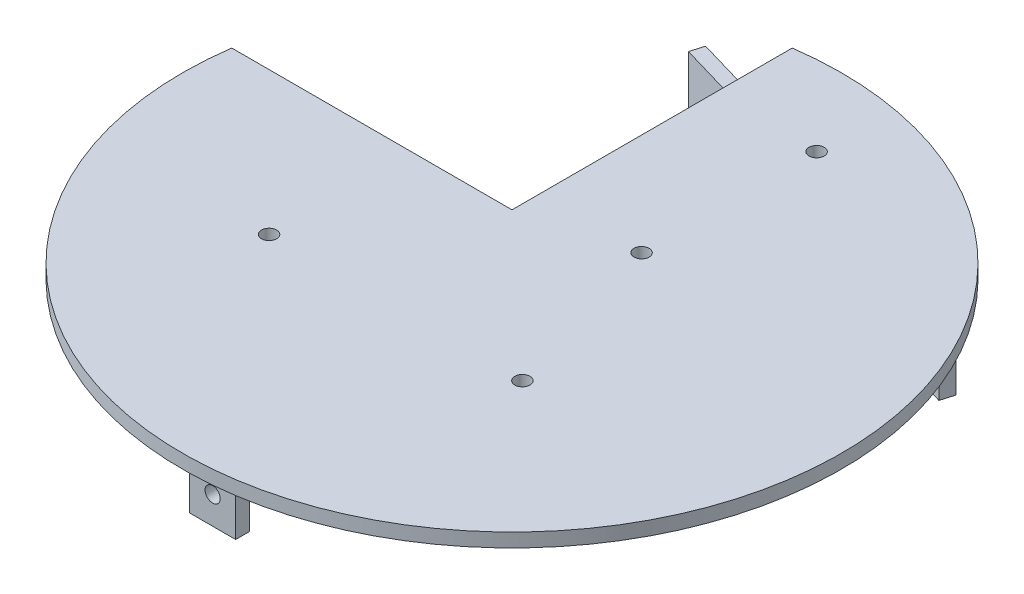
from build123d import *

# Parameters (mm, degrees)
SKETCH1_R           = 1.65
BOSS_EXTRUDE1_DEPTH = 3
BOSS_EXTRUDE2_DEPTH = 16
SKETCH3_R           = 1.65
CUT_EXTRUDE1_DEPTH  = 16
SKETCH5_W           = 10
SKETCH5_H           = 3
BOSS_EXTRUDE3_DEPTH = 14
SKETCH6_R           = 1.65
CUT_EXTRUDE2_DEPTH  = 14


with BuildPart() as part:
    # Sketch1 → Boss-Extrude1 (new body)
    with BuildSketch(Plane(origin=(0, 0, 0), x_dir=(1, 0, 0), z_dir=(0, 1, 0))):
        with BuildLine():
            Line((-10, 70.842692107), (-10, 10))
            Line((-10, 10), (-70.842692107, 10))
            ThreePointArc((-70.842692107, 10), (-71.369207057, 5.012315742), (-71.545, 0))
            ThreePointArc((-71.545, 0), (50.58995466, -50.58995466), (0, 71.545))
            ThreePointArc((0, 71.545), (-5.012315742, 71.369207057), (-10, 70.842692107))
        make_face()
        with Locations((12.13, 16)):
            Circle(SKETCH1_R, mode=Mode.SUBTRACT)
        with Locations((12.13, 54)):
            Circle(SKETCH1_R, mode=Mode.SUBTRACT)
        with Locations((23.25, -21)):
            Circle(SKETCH1_R, mode=Mode.SUBTRACT)
        with Locations((-31.75, -21)):
            Circle(SKETCH1_R, mode=Mode.SUBTRACT)
    extrude(amount=BOSS_EXTRUDE1_DEPTH)

    # Sketch2 → Boss-Extrude2 (add)
    with BuildSketch(Plane.XZ):
        Polygon((-23.600230141, -61.909816502), (53.19593923, -39.496687094), (54.036431583, -42.376543445), (-22.759737789, -64.789672853), align=None)
    extrude(amount=BOSS_EXTRUDE2_DEPTH)

    # Sketch3 → Cut-Extrude1 (cut)
    with BuildSketch(Plane(origin=(14.797854544, 0, -50.703251798), x_dir=(0.959952117, 0, 0.280164118), z_dir=(-0.280164118, 0, 0.959952117))):
        with Locations((-31, -8)):
            Circle(SKETCH3_R)
        with Locations((31, -8)):
            Circle(SKETCH3_R)
    extrude(amount=-CUT_EXTRUDE1_DEPTH, mode=Mode.SUBTRACT)

    # Sketch5 → Boss-Extrude3 (add)
    with BuildSketch(Plane(origin=(0, 0, 0), x_dir=(-1, 0, 0), z_dir=(0, -1, 0))):
        with Locations((0, -63.5)):
            Rectangle(SKETCH5_W, SKETCH5_H)
    extrude(amount=BOSS_EXTRUDE3_DEPTH)

    # Sketch6 → Cut-Extrude2 (cut)
    with BuildSketch(Plane(origin=(0, 0, 62), x_dir=(-1, 0, 0), z_dir=(0, 0, -1))):
        with Locations((0, -7.998816604)):
            Circle(SKETCH6_R)
    extrude(amount=-CUT_EXTRUDE2_DEPTH, mode=Mode.SUBTRACT)


solid = part.part
